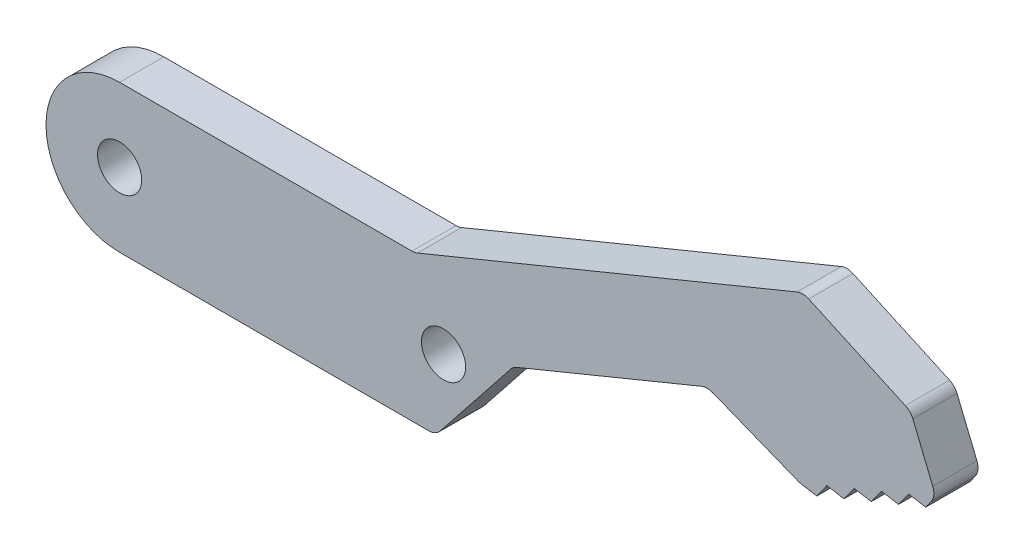
from build123d import *

# Parameters (mm, degrees)
SKETCH1_R           = 1.5
BOSS_EXTRUDE1_DEPTH = 3
FILLET1_R           = 1


with BuildPart() as part:
    # Sketch1 → Boss-Extrude1 (new body)
    with BuildSketch(Plane.XY):
        with BuildLine():
            Line((20.05, 5), (0, 5))
            ThreePointArc((0, 5), (-5, 0), (0, -5))
            Line((0, -5), (21.474824475, -5))
            Line((21.474824475, -5), (26.72989842, 1.621129525))
            Line((26.72989842, 1.621129525), (39.900164389, 7.036080522))
            Line((39.900164389, 7.036080522), (46.188488025, 4.540007042))
            Line((46.188488025, 4.540007042), (47.351030887, 4.342221563))
            Line((47.351030887, 4.342221563), (48.038244482, 5.300533868))
            Line((48.038244482, 5.300533868), (49.200787343, 5.102748388))
            Line((49.200787343, 5.102748388), (49.888000938, 6.061060693))
            Line((49.888000938, 6.061060693), (51.050543799, 5.863275214))
            Line((51.050543799, 5.863275214), (51.737757394, 6.821587519))
            Line((51.737757394, 6.821587519), (52.900300256, 6.623802039))
            Line((52.900300256, 6.623802039), (53.587513851, 7.582114344))
            Line((53.587513851, 7.582114344), (54.750056712, 7.384328864))
            Line((54.750056712, 7.384328864), (55.437270307, 8.34264117))
            Line((55.437270307, 8.34264117), (53.72608495, 12.504593197))
            Line((53.72608495, 12.504593197), (46.409029503, 15.837507263))
            Line((46.409029503, 15.837507263), (20.05, 5))
        make_face()
        Circle(SKETCH1_R, mode=Mode.SUBTRACT)
        with Locations((22, 0)):
            Circle(SKETCH1_R, mode=Mode.SUBTRACT)
    extrude(amount=BOSS_EXTRUDE1_DEPTH)

    # Fillet1
    fillet1_edges = [part.edges().sort_by_distance(p)[0] for p in [
        (21.474824475, -5, 1.5),
        (20.05, 5, 1.5),
        (46.409029503, 15.837507263, 1.5),
        (53.72608495, 12.504593197, 1.5),
        (55.437270307, 8.34264117, 1.5),
        (46.188488025, 4.540007042, 1.5),
        (39.900164389, 7.036080522, 1.5),
        (26.72989842, 1.621129525, 1.5),
    ]]
    fillet(fillet1_edges, radius=FILLET1_R)


solid = part.part
